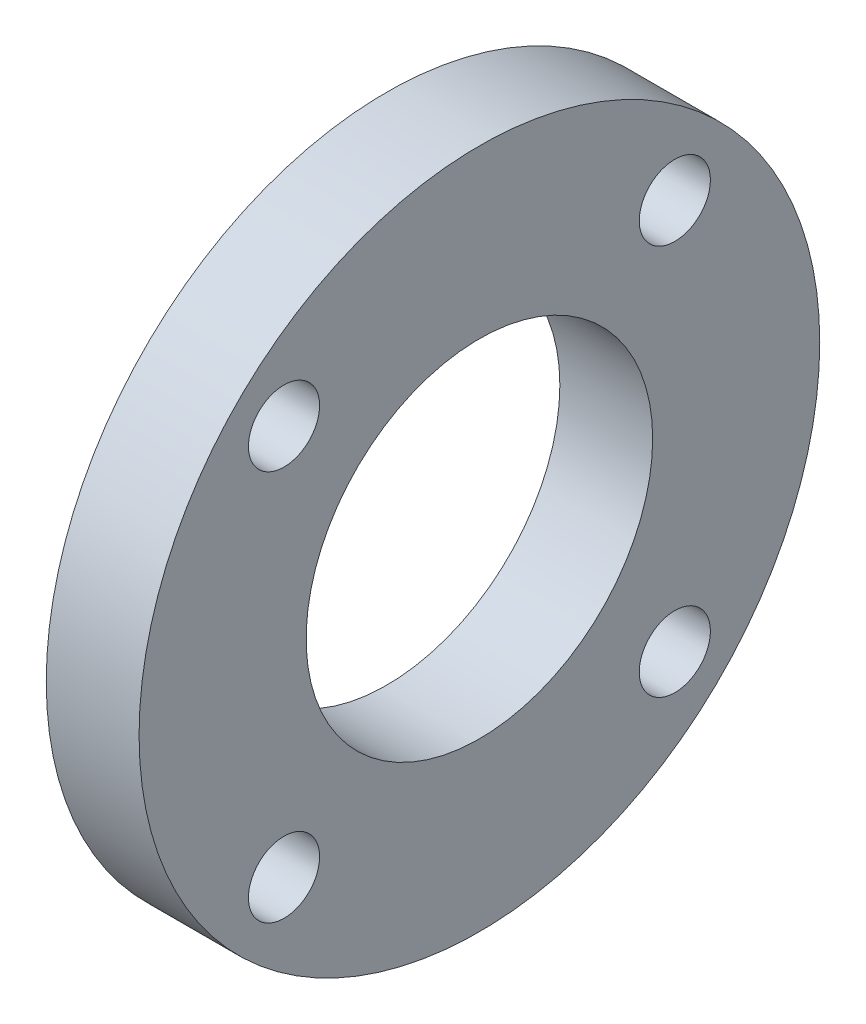
from build123d import *

# Parameters (mm, degrees)
SKETCH2_R           = 11
SKETCH2_R_2         = 5.6
BOSS_EXTRUDE1_DEPTH = 3
SKETCH3_R           = 1.15
CUT_EXTRUDE1_DEPTH  = 4


with BuildPart() as part:
    # Sketch2 → Boss-Extrude1 (new body)
    with BuildSketch(Plane(origin=(0, 0, 0), x_dir=(0, 0, -1), z_dir=(1, 0, 0))):
        Circle(SKETCH2_R)
        Circle(SKETCH2_R_2, mode=Mode.SUBTRACT)
    extrude(amount=BOSS_EXTRUDE1_DEPTH)

    # Sketch3 → Cut-Extrude1 (cut, through all)
    with BuildSketch(Plane(origin=(0, 0, 0), x_dir=(0, 0, -1), z_dir=(1, 0, 0))):
        with Locations((6.315465173, 6.315465173)):
            Circle(SKETCH3_R)
        with Locations((6.315465173, -6.315465173)):
            Circle(SKETCH3_R)
        with Locations((-6.315465173, -6.315465173)):
            Circle(SKETCH3_R)
        with Locations((-6.315465173, 6.315465173)):
            Circle(SKETCH3_R)
    extrude(amount=CUT_EXTRUDE1_DEPTH, mode=Mode.SUBTRACT)


solid = part.part
